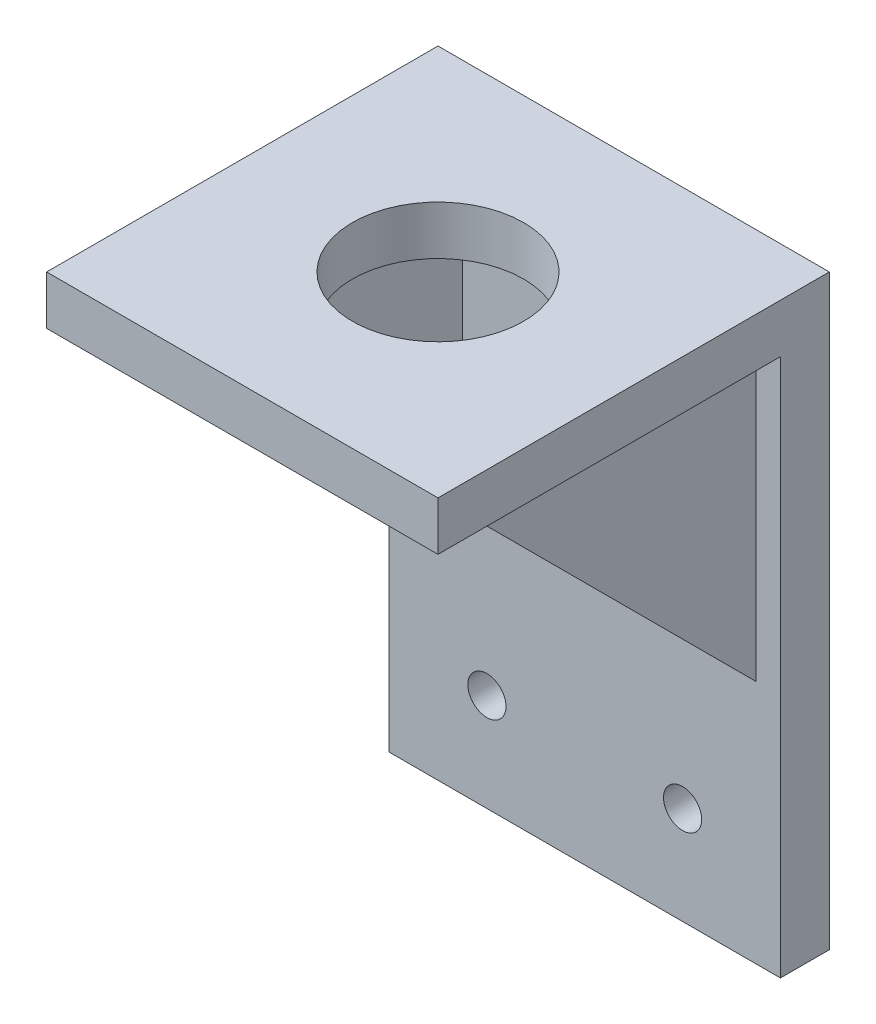
from build123d import *

# Parameters (mm, degrees)
SKETCH1_W           = 50.8
SKETCH1_H           = 76.2
SKETCH1_R           = 2.4765
BOSS_EXTRUDE1_DEPTH = 6.35
SKETCH2_R           = 2.2225
BOSS_EXTRUDE2_DEPTH = 3.175
SKETCH3_W           = 6.35
SKETCH3_H           = 3.175
CUT_EXTRUDE1_DEPTH  = 10.525
SKETCH4_W           = 50.8
SKETCH4_H           = 44.45
BOSS_EXTRUDE3_DEPTH = 6.35
BOSS_EXTRUDE4_DEPTH = 22.225
SKETCH6_W           = 31.75
SKETCH6_H           = 38.1
CUT_EXTRUDE2_DEPTH  = 45.45
SKETCH7_R           = 11.1125
CUT_EXTRUDE3_DEPTH  = 7.35


with BuildPart() as part:
    # Sketch1 → Boss-Extrude1 (new body)
    with BuildSketch(Plane.XY):
        Rectangle(SKETCH1_W, SKETCH1_H)
        with Locations((-12.7, -25.4)):
            Circle(SKETCH1_R, mode=Mode.SUBTRACT)
        with Locations((12.7, -25.4)):
            Circle(SKETCH1_R, mode=Mode.SUBTRACT)
        with Locations((0, 25.4)):
            Circle(SKETCH1_R, mode=Mode.SUBTRACT)
    extrude(amount=BOSS_EXTRUDE1_DEPTH)

    # Sketch2 → Boss-Extrude2 (add)
    with BuildSketch(Plane(origin=(0, 0, 0), x_dir=(-1, 0, 0), z_dir=(0, 0, -1))):
        with Locations((-12.7, 25.4)):
            Circle(SKETCH2_R)
        with Locations((12.7, 25.4)):
            Circle(SKETCH2_R)
        with BuildLine():
            ThreePointArc((-4.7625, 13.470384182), (-7.14375, 12.373337957), (-9.2844449, 10.859638076))
            ThreePointArc((-9.2844449, 10.859638076), (-10.480991316, 10.354281134), (-11.74973534, 10.632485314))
            ThreePointArc((-11.74973534, 10.632485314), (-13.110218123, 10.843506493), (-14.257611096, 10.082630217))
            ThreePointArc((-14.257611096, 10.082630217), (-15.122968614, 8.73125), (-15.860619453, 7.306138298))
            ThreePointArc((-15.860619453, 7.306138298), (-15.94586115, 5.932028698), (-15.082870058, 4.859326635))
            ThreePointArc((-15.082870058, 4.859326635), (-14.207566158, 3.899664169), (-14.0469449, 2.610746105))
            ThreePointArc((-14.0469449, 2.610746105), (-14.2875, 0), (-14.0469449, -2.610746105))
            ThreePointArc((-14.0469449, -2.610746105), (-14.207566158, -3.899664169), (-15.082870058, -4.859326635))
            ThreePointArc((-15.082870058, -4.859326635), (-15.94586115, -5.932028698), (-15.860619453, -7.306138298))
            ThreePointArc((-15.860619453, -7.306138298), (-15.122968614, -8.73125), (-14.257611096, -10.082630217))
            ThreePointArc((-14.257611096, -10.082630217), (-13.110218123, -10.843506493), (-11.74973534, -10.632485314))
            ThreePointArc((-11.74973534, -10.632485314), (-10.480991316, -10.354281134), (-9.2844449, -10.859638076))
            ThreePointArc((-9.2844449, -10.859638076), (-7.14375, -12.373337957), (-4.7625, -13.470384182))
            ThreePointArc((-4.7625, -13.470384182), (-3.726574842, -14.253945304), (-3.333134718, -15.491811949))
            ThreePointArc((-3.333134718, -15.491811949), (-2.835643027, -16.77553519), (-1.603008357, -17.388768515))
            ThreePointArc((-1.603008357, -17.388768515), (0, -17.4625), (1.603008357, -17.388768515))
            ThreePointArc((1.603008357, -17.388768515), (2.835643027, -16.77553519), (3.333134718, -15.491811949))
            ThreePointArc((3.333134718, -15.491811949), (3.726574842, -14.253945304), (4.7625, -13.470384182))
            ThreePointArc((4.7625, -13.470384182), (7.14375, -12.373337957), (9.2844449, -10.859638076))
            ThreePointArc((9.2844449, -10.859638076), (10.480991316, -10.354281134), (11.74973534, -10.632485314))
            ThreePointArc((11.74973534, -10.632485314), (13.110218123, -10.843506493), (14.257611096, -10.082630217))
            ThreePointArc((14.257611096, -10.082630217), (15.122968614, -8.73125), (15.860619453, -7.306138298))
            ThreePointArc((15.860619453, -7.306138298), (15.94586115, -5.932028698), (15.082870058, -4.859326635))
            ThreePointArc((15.082870058, -4.859326635), (14.207566158, -3.899664169), (14.0469449, -2.610746105))
            ThreePointArc((14.0469449, -2.610746105), (14.2875, 0), (14.0469449, 2.610746105))
            ThreePointArc((14.0469449, 2.610746105), (14.207566158, 3.899664169), (15.082870058, 4.859326635))
            ThreePointArc((15.082870058, 4.859326635), (15.94586115, 5.932028698), (15.860619453, 7.306138298))
            ThreePointArc((15.860619453, 7.306138298), (15.122968614, 8.73125), (14.257611096, 10.082630217))
            ThreePointArc((14.257611096, 10.082630217), (13.110218123, 10.843506493), (11.74973534, 10.632485314))
            ThreePointArc((11.74973534, 10.632485314), (10.480991316, 10.354281134), (9.2844449, 10.859638076))
            ThreePointArc((9.2844449, 10.859638076), (7.14375, 12.373337957), (4.7625, 13.470384182))
            ThreePointArc((4.7625, 13.470384182), (3.726574842, 14.253945304), (3.333134718, 15.491811949))
            ThreePointArc((3.333134718, 15.491811949), (2.835643027, 16.77553519), (1.603008357, 17.388768515))
            ThreePointArc((1.603008357, 17.388768515), (0, 17.4625), (-1.603008357, 17.388768515))
            ThreePointArc((-1.603008357, 17.388768515), (-2.835643027, 16.77553519), (-3.333134718, 15.491811949))
            ThreePointArc((-3.333134718, 15.491811949), (-3.726574842, 14.253945304), (-4.7625, 13.470384182))
        make_face()
    extrude(amount=BOSS_EXTRUDE2_DEPTH)

    # Sketch3 → Cut-Extrude1 (cut, through all)
    with BuildSketch(Plane(origin=(0, 0, -3.175), x_dir=(-1, 0, 0), z_dir=(0, 0, -1))):
        Rectangle(SKETCH3_W, SKETCH3_H)
    extrude(amount=-CUT_EXTRUDE1_DEPTH, mode=Mode.SUBTRACT)

    # Sketch4 → Boss-Extrude3 (add)
    with BuildSketch(Plane(origin=(0, 38.1, 0), x_dir=(1, 0, 0), z_dir=(0, 1, 0))):
        with Locations((0, -28.575)):
            Rectangle(SKETCH4_W, SKETCH4_H)
    extrude(amount=-BOSS_EXTRUDE3_DEPTH)

    # Sketch5 → Boss-Extrude4 (add, symmetric)
    with BuildSketch(Plane(origin=(0, 0, 0), x_dir=(0, 0, -1), z_dir=(1, 0, 0))):
        Polygon((-44.45, 31.75), (-6.35, -6.35), (-6.35, 31.75), align=None)
    extrude(amount=BOSS_EXTRUDE4_DEPTH, both=True)

    # Sketch6 → Cut-Extrude2 (cut, through all)
    with BuildSketch(Plane.XY.offset(6.35)):
        with Locations((0, 12.7)):
            Rectangle(SKETCH6_W, SKETCH6_H)
    extrude(amount=CUT_EXTRUDE2_DEPTH, mode=Mode.SUBTRACT)

    # Sketch7 → Cut-Extrude3 (cut, through all)
    with BuildSketch(Plane.XZ.offset(-31.75)):
        with Locations((0, 25.4)):
            Circle(SKETCH7_R)
    extrude(amount=-CUT_EXTRUDE3_DEPTH, mode=Mode.SUBTRACT)


solid = part.part
